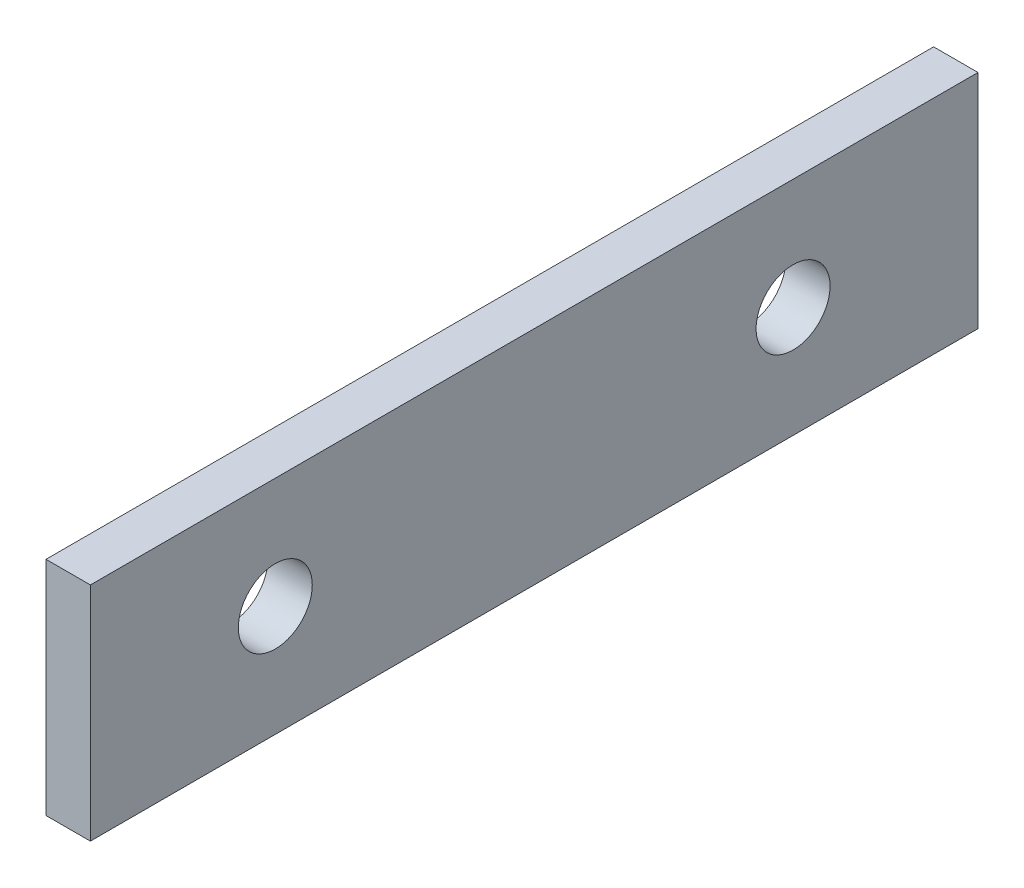
from build123d import *

# Parameters (mm, degrees)
SKETCH1_W           = 60
SKETCH1_H           = 15
SKETCH1_R           = 2.5
BOSS_EXTRUDE1_DEPTH = 3


with BuildPart() as part:
    # Sketch1 → Boss-Extrude1 (new body)
    with BuildSketch(Plane(origin=(0, 0, 0), x_dir=(0, 0, -1), z_dir=(1, 0, 0))):
        with Locations((0, -7.5)):
            Rectangle(SKETCH1_W, SKETCH1_H)
        with Locations((-17.5, -7.5)):
            Circle(SKETCH1_R, mode=Mode.SUBTRACT)
        with Locations((17.5, -7.5)):
            Circle(SKETCH1_R, mode=Mode.SUBTRACT)
    extrude(amount=BOSS_EXTRUDE1_DEPTH)


solid = part.part
